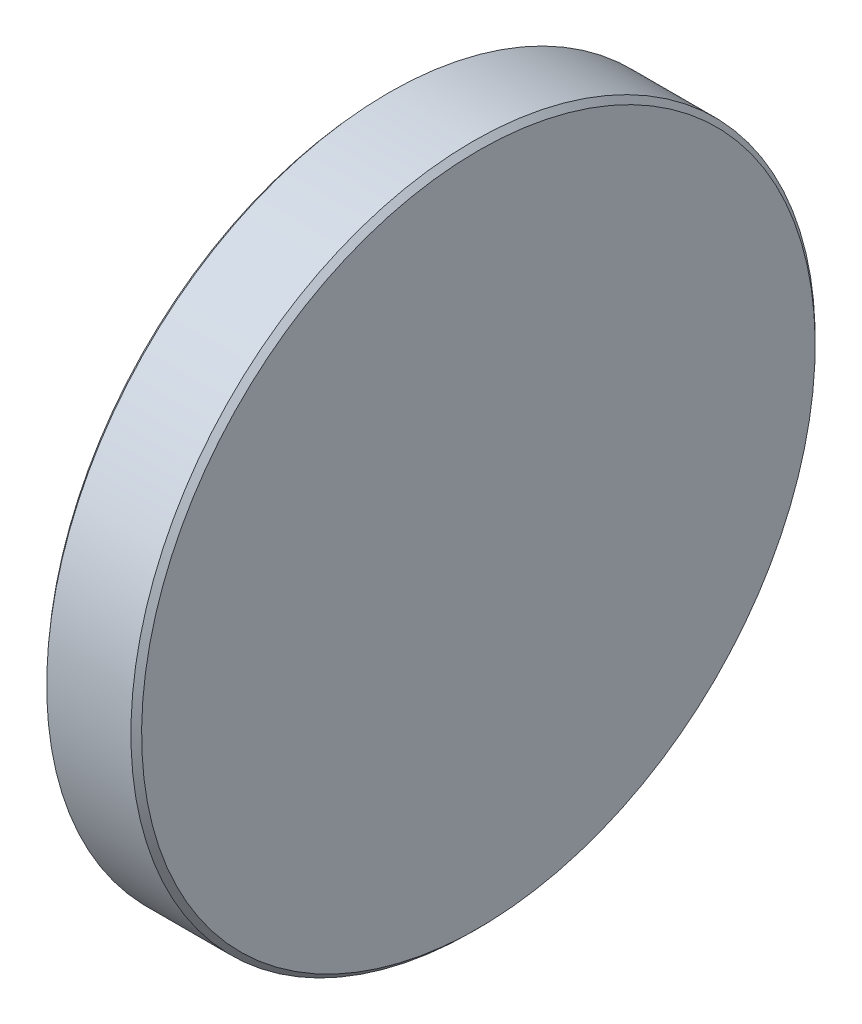
from build123d import *

# Parameters (mm, degrees)
CHAMFER_1_SIZE2       = 0.25
CHAMFER_1_SIZE        = 0.237681877
CHAMFER_1_EDGE_2_SIZE = 0.25


with BuildPart() as part:
    # Эскиз1 → Повернуть1 (revolve)
    with BuildSketch(Plane.XY):
        with BuildLine():
            Line((-0.426259063, 16), (4, 16))
            Line((4, 16), (4, 0))
            Line((4, 0), (0, 0))
            ThreePointArc((0, 0), (-0.106583668, 8.002838509), (-0.426259063, 16))
        make_face()
    revolve(axis=Axis((4, 0, 0), (-1, 0, 0)))

    # Фаска1
    chamfer_1_edges = [part.edges().sort_by_distance(p)[0] for p in [
        (-0.426259063, -16, 0),
    ]]
    chamfer(chamfer_1_edges, length=CHAMFER_1_SIZE, length2=CHAMFER_1_SIZE2)

    # Фаска1 edge 2
    chamfer_1_edge_2_edges = [part.edges().sort_by_distance(p)[0] for p in [
        (4, -16, 0),
    ]]
    chamfer(chamfer_1_edge_2_edges, length=CHAMFER_1_EDGE_2_SIZE)


solid = part.part
